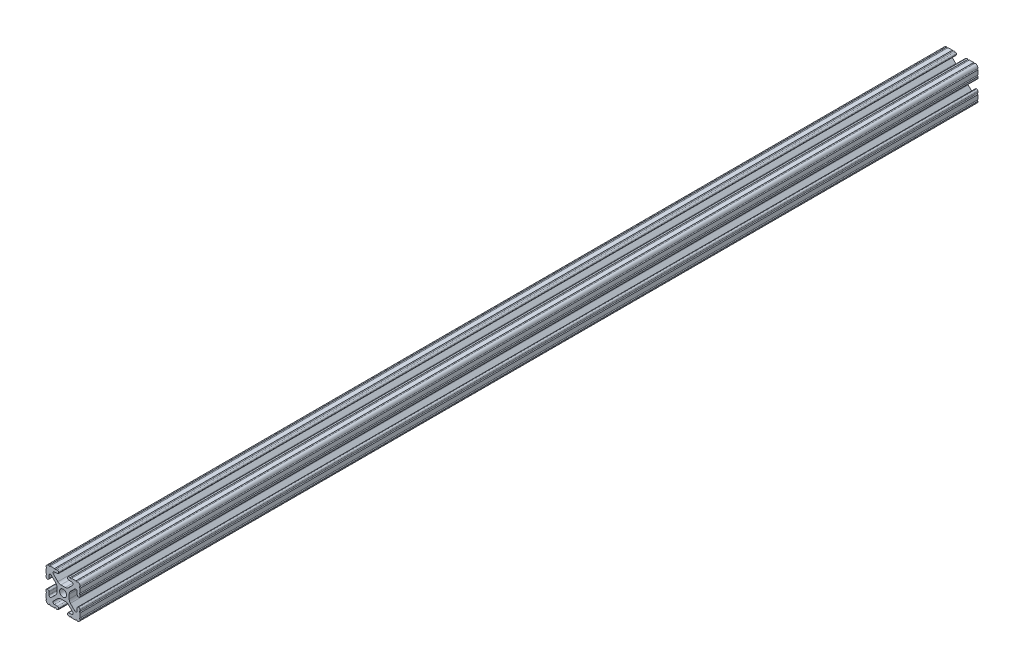
from build123d import *

# Parameters (mm, degrees)
SKETCH1_R           = 2.6035
BOSS_EXTRUDE1_DEPTH = 914.4
SKETCH2_W           = 76.348142357
SKETCH2_H           = 34.760821459
SKETCH2_W_2         = 1099.97900941
SKETCH2_H_2         = 36.169365112
CUT_EXTRUDE1_DEPTH  = 27.432


with BuildPart() as part:
    # Sketch1 → Boss-Extrude1 (new body, symmetric)
    with BuildSketch(Plane.XY):
        with BuildLine():
            Line((-7.179650497, -8.645192506), (-3.952270251, -5.423690499))
            ThreePointArc((-3.952270251, -5.423690499), (-2.922936451, -4.736929036), (-1.709253557, -4.4958))
            Line((-1.709253557, -4.4958), (1.709253557, -4.4958))
            ThreePointArc((1.709253557, -4.4958), (2.922936451, -4.736929036), (3.952270251, -5.423690499))
            Line((3.952270251, -5.423690499), (7.179650497, -8.645192506))
            ThreePointArc((7.179650497, -8.645192506), (7.41473083, -9.822813117), (6.416408329, -10.4902))
            Line((6.416408329, -10.4902), (4.287512407, -10.4902))
            ThreePointArc((4.287512407, -10.4902), (3.54574862, -10.79744862), (3.2385, -11.539212407))
            Line((3.2385, -11.539212407), (3.2385, -11.650987593))
            ThreePointArc((3.2385, -11.650987593), (3.54574862, -12.39275138), (4.287512407, -12.7))
            Line((4.287512407, -12.7), (5.317126718, -12.7))
            ThreePointArc((5.317126718, -12.7), (5.825126718, -12.192), (6.333126718, -12.7))
            Line((6.333126718, -12.7), (9.550443118, -12.7))
            ThreePointArc((9.550443118, -12.7), (10.058366869, -12.192000006), (10.566443095, -12.699847501))
            ThreePointArc((10.566443095, -12.699847501), (12.082537762, -12.08250727), (12.699846982, -10.566399977))
            ThreePointArc((12.699846982, -10.566399977), (12.192000006, -10.058323491), (12.7, -9.5504))
            Line((12.7, -9.5504), (12.7, -6.3330836))
            ThreePointArc((12.7, -6.3330836), (12.192, -5.8250836), (12.7, -5.3170836))
            Line((12.7, -5.3170836), (12.7, -4.287469289))
            ThreePointArc((12.7, -4.287469289), (12.39275138, -3.545705502), (11.650987593, -3.238456882))
            Line((11.650987593, -3.238456882), (11.539212407, -3.238456882))
            ThreePointArc((11.539212407, -3.238456882), (10.79744862, -3.545705502), (10.4902, -4.287469289))
            Line((10.4902, -4.287469289), (10.4902, -6.402089023))
            ThreePointArc((10.4902, -6.402089023), (9.856505071, -7.351067942), (8.737131347, -7.129408934))
            Line((8.737131347, -7.129408934), (5.441005833, -3.840816462))
            ThreePointArc((5.441005833, -3.840816462), (4.750877967, -2.809883091), (4.5085, -1.593185507))
            Line((4.5085, -1.593185507), (4.5085, 1.593185507))
            ThreePointArc((4.5085, 1.593185507), (4.750877967, 2.809883091), (5.441005833, 3.840816462))
            Line((5.441005833, 3.840816462), (8.737131347, 7.129408934))
            ThreePointArc((8.737131347, 7.129408934), (9.856505071, 7.351067942), (10.4902, 6.402089023))
            Line((10.4902, 6.402089023), (10.4902, 4.287469289))
            ThreePointArc((10.4902, 4.287469289), (10.79744862, 3.545705502), (11.539212407, 3.238456882))
            Line((11.539212407, 3.238456882), (11.650987593, 3.238456882))
            ThreePointArc((11.650987593, 3.238456882), (12.39275138, 3.545705502), (12.7, 4.287469289))
            Line((12.7, 4.287469289), (12.7, 5.3170836))
            ThreePointArc((12.7, 5.3170836), (12.192, 5.8250836), (12.7, 6.3330836))
            Line((12.7, 6.3330836), (12.7, 9.5504))
            ThreePointArc((12.7, 9.5504), (12.192000006, 10.058323491), (12.699846982, 10.566399977))
            ThreePointArc((12.699846982, 10.566399977), (12.082537762, 12.08250727), (10.566443095, 12.699847501))
            ThreePointArc((10.566443095, 12.699847501), (10.058366869, 12.192000006), (9.550443118, 12.7))
            Line((9.550443118, 12.7), (6.333126718, 12.7))
            ThreePointArc((6.333126718, 12.7), (5.825126718, 12.192), (5.317126718, 12.7))
            Line((5.317126718, 12.7), (4.287512407, 12.7))
            ThreePointArc((4.287512407, 12.7), (3.54574862, 12.39275138), (3.2385, 11.650987593))
            Line((3.2385, 11.650987593), (3.2385, 11.539212407))
            ThreePointArc((3.2385, 11.539212407), (3.54574862, 10.79744862), (4.287512407, 10.4902))
            Line((4.287512407, 10.4902), (6.476788598, 10.4902))
            ThreePointArc((6.476788598, 10.4902), (7.432222385, 9.85140422), (7.207036008, 8.724370562))
            Line((7.207036008, 8.724370562), (3.898272566, 5.423169045))
            ThreePointArc((3.898272566, 5.423169045), (2.869120213, 4.736787962), (1.655778399, 4.4958))
            Line((1.655778399, 4.4958), (-1.655778399, 4.4958))
            ThreePointArc((-1.655778399, 4.4958), (-2.869120213, 4.736787962), (-3.898272566, 5.423169045))
            Line((-3.898272566, 5.423169045), (-7.207036008, 8.724370562))
            ThreePointArc((-7.207036008, 8.724370562), (-7.432222385, 9.85140422), (-6.476788598, 10.4902))
            Line((-6.476788598, 10.4902), (-4.287512407, 10.4902))
            ThreePointArc((-4.287512407, 10.4902), (-3.54574862, 10.79744862), (-3.2385, 11.539212407))
            Line((-3.2385, 11.539212407), (-3.2385, 11.650987593))
            ThreePointArc((-3.2385, 11.650987593), (-3.54574862, 12.39275138), (-4.287512407, 12.7))
            Line((-4.287512407, 12.7), (-5.317126718, 12.7))
            ThreePointArc((-5.317126718, 12.7), (-5.825126718, 12.192), (-6.333126718, 12.7))
            Line((-6.333126718, 12.7), (-9.550443118, 12.7))
            ThreePointArc((-9.550443118, 12.7), (-10.058366869, 12.192000006), (-10.566443095, 12.699847501))
            ThreePointArc((-10.566443095, 12.699847501), (-12.082537762, 12.08250727), (-12.699846982, 10.566399977))
            ThreePointArc((-12.699846982, 10.566399977), (-12.192000006, 10.058323491), (-12.7, 9.5504))
            Line((-12.7, 9.5504), (-12.7, 6.3330836))
            ThreePointArc((-12.7, 6.3330836), (-12.192, 5.8250836), (-12.7, 5.3170836))
            Line((-12.7, 5.3170836), (-12.7, 4.287469289))
            ThreePointArc((-12.7, 4.287469289), (-12.39275138, 3.545705502), (-11.650987593, 3.238456882))
            Line((-11.650987593, 3.238456882), (-11.539212407, 3.238456882))
            ThreePointArc((-11.539212407, 3.238456882), (-10.79744862, 3.545705502), (-10.4902, 4.287469289))
            Line((-10.4902, 4.287469289), (-10.4902, 6.402089023))
            ThreePointArc((-10.4902, 6.402089023), (-9.856505071, 7.351067942), (-8.737131347, 7.129408934))
            Line((-8.737131347, 7.129408934), (-5.441005833, 3.840816462))
            ThreePointArc((-5.441005833, 3.840816462), (-4.750877967, 2.809883091), (-4.5085, 1.593185507))
            Line((-4.5085, 1.593185507), (-4.5085, -1.593185507))
            ThreePointArc((-4.5085, -1.593185507), (-4.750877967, -2.809883091), (-5.441005833, -3.840816462))
            Line((-5.441005833, -3.840816462), (-8.737131347, -7.129408934))
            ThreePointArc((-8.737131347, -7.129408934), (-9.856505071, -7.351067942), (-10.4902, -6.402089023))
            Line((-10.4902, -6.402089023), (-10.4902, -4.287469289))
            ThreePointArc((-10.4902, -4.287469289), (-10.79744862, -3.545705502), (-11.539212407, -3.238456882))
            Line((-11.539212407, -3.238456882), (-11.650987593, -3.238456882))
            ThreePointArc((-11.650987593, -3.238456882), (-12.39275138, -3.545705502), (-12.7, -4.287469289))
            Line((-12.7, -4.287469289), (-12.7, -5.3170836))
            ThreePointArc((-12.7, -5.3170836), (-12.192, -5.8250836), (-12.7, -6.3330836))
            Line((-12.7, -6.3330836), (-12.7, -9.5504))
            ThreePointArc((-12.7, -9.5504), (-12.192000006, -10.058323491), (-12.699846982, -10.566399977))
            ThreePointArc((-12.699846982, -10.566399977), (-12.082537762, -12.08250727), (-10.566443095, -12.699847501))
            ThreePointArc((-10.566443095, -12.699847501), (-10.058366869, -12.192000006), (-9.550443118, -12.7))
            Line((-9.550443118, -12.7), (-6.333126718, -12.7))
            ThreePointArc((-6.333126718, -12.7), (-5.825126718, -12.192), (-5.317126718, -12.7))
            Line((-5.317126718, -12.7), (-4.287512407, -12.7))
            ThreePointArc((-4.287512407, -12.7), (-3.54574862, -12.39275138), (-3.2385, -11.650987593))
            Line((-3.2385, -11.650987593), (-3.2385, -11.539212407))
            ThreePointArc((-3.2385, -11.539212407), (-3.54574862, -10.79744862), (-4.287512407, -10.4902))
            Line((-4.287512407, -10.4902), (-6.416408329, -10.4902))
            ThreePointArc((-6.416408329, -10.4902), (-7.41473083, -9.822813117), (-7.179650497, -8.645192506))
        make_face()
        Circle(SKETCH1_R, mode=Mode.SUBTRACT)
    extrude(amount=BOSS_EXTRUDE1_DEPTH, both=True)

    # Sketch2 → Cut-Extrude1 (cut)
    with BuildSketch(Plane(origin=(12.7, 0, 0), x_dir=(0, 0, -1), z_dir=(1, 0, 0))):
        with Locations((-880.283201428, -0.58573738)):
            Rectangle(SKETCH2_W, SKETCH2_H)
        with Locations((375.067711741, 0.118534447)):
            Rectangle(SKETCH2_W_2, SKETCH2_H_2)
    extrude(amount=-CUT_EXTRUDE1_DEPTH, mode=Mode.SUBTRACT)


solid = part.part
